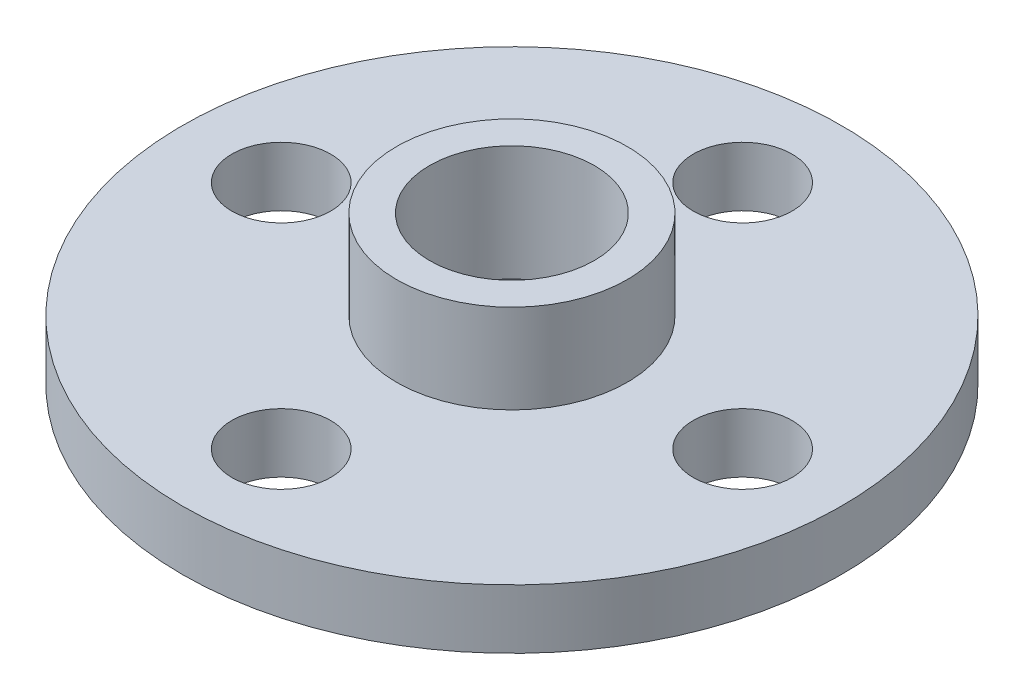
from build123d import *

# Parameters (mm, degrees)
SKETCH1_R           = 10
SKETCH1_R_2         = 2.5
SKETCH1_R_3         = 1.5
BOSS_EXTRUDE1_DEPTH = 1.8
SKETCH2_R           = 3.5
SKETCH2_R_2         = 2.5
BOSS_EXTRUDE2_DEPTH = 2.7
SKETCH3_R           = 2.5
BOSS_EXTRUDE3_DEPTH = 1


with BuildPart() as part:
    # Sketch1 → Boss-Extrude1 (new body)
    with BuildSketch(Plane(origin=(0, 0, 0), x_dir=(1, 0, 0), z_dir=(0, 1, 0))):
        Circle(SKETCH1_R)
        Circle(SKETCH1_R_2, mode=Mode.SUBTRACT)
        with Locations((0, 7)):
            Circle(SKETCH1_R_3, mode=Mode.SUBTRACT)
        with Locations((7, 0)):
            Circle(SKETCH1_R_3, mode=Mode.SUBTRACT)
        with Locations((0, -7)):
            Circle(SKETCH1_R_3, mode=Mode.SUBTRACT)
        with Locations((-7, 0)):
            Circle(SKETCH1_R_3, mode=Mode.SUBTRACT)
    extrude(amount=BOSS_EXTRUDE1_DEPTH)

    # Sketch2 → Boss-Extrude2 (add)
    with BuildSketch(Plane(origin=(0, 1.8, 0), x_dir=(1, 0, 0), z_dir=(0, 1, 0))):
        Circle(SKETCH2_R)
        Circle(SKETCH2_R_2, mode=Mode.SUBTRACT)
    extrude(amount=BOSS_EXTRUDE2_DEPTH)

    # Sketch3 → Boss-Extrude3 (add)
    with BuildSketch(Plane(origin=(0, 0, 0), x_dir=(-1, 0, 0), z_dir=(0, -1, 0))):
        Circle(SKETCH3_R)
    extrude(amount=-BOSS_EXTRUDE3_DEPTH)


solid = part.part
